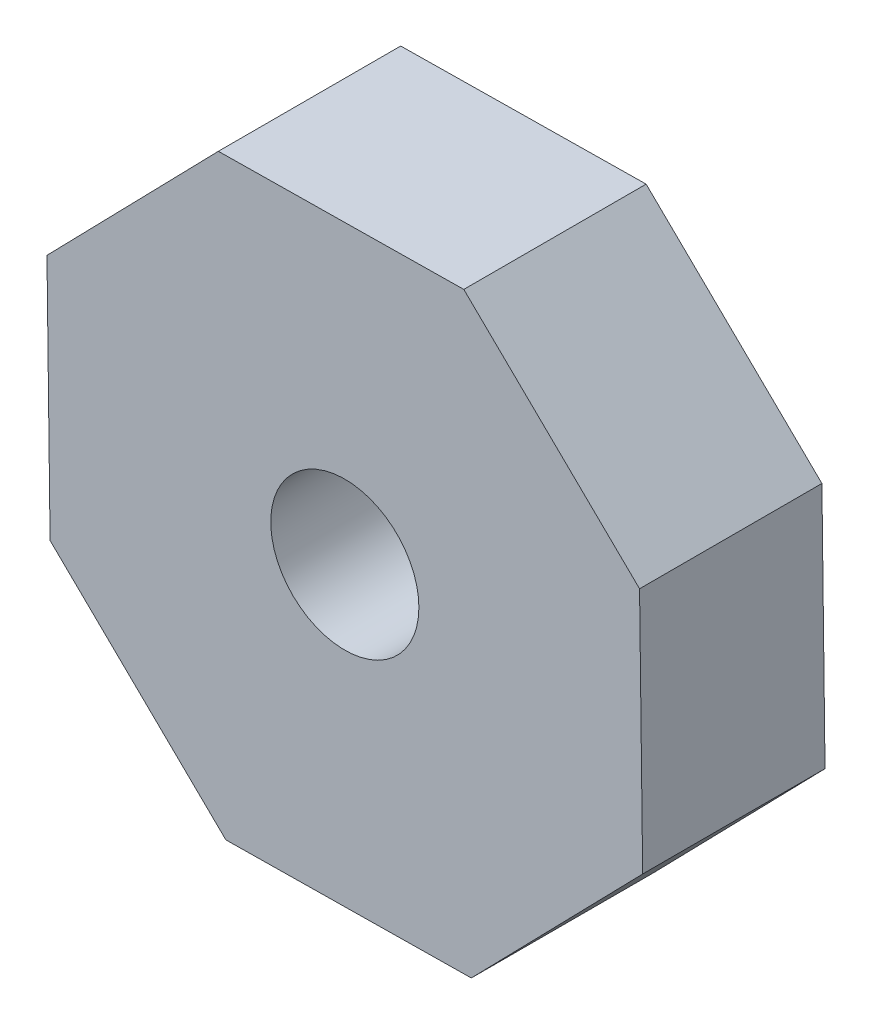
from build123d import *

# Parameters (mm, degrees)
BOSS_EXTRUDE1_DEPTH = 4
SKETCH2_R           = 1.625
CUT_EXTRUDE1_DEPTH  = 5


with BuildPart() as part:
    # Sketch1 → Boss-Extrude1 (new body)
    with BuildSketch(Plane.XY):
        Polygon((6.465324726, 2.774622528), (2.609720552, 6.533629361), (-2.774622528, 6.465324726), (-6.533629361, 2.609720552), (-6.465324726, -2.774622528), (-2.609720552, -6.533629361), (2.774622528, -6.465324726), (6.533629361, -2.609720552), align=None)
    extrude(amount=BOSS_EXTRUDE1_DEPTH)

    # Sketch2 → Cut-Extrude1 (cut, through all)
    with BuildSketch(Plane.XY.offset(4)):
        Circle(SKETCH2_R)
    extrude(amount=-CUT_EXTRUDE1_DEPTH, mode=Mode.SUBTRACT)


solid = part.part
